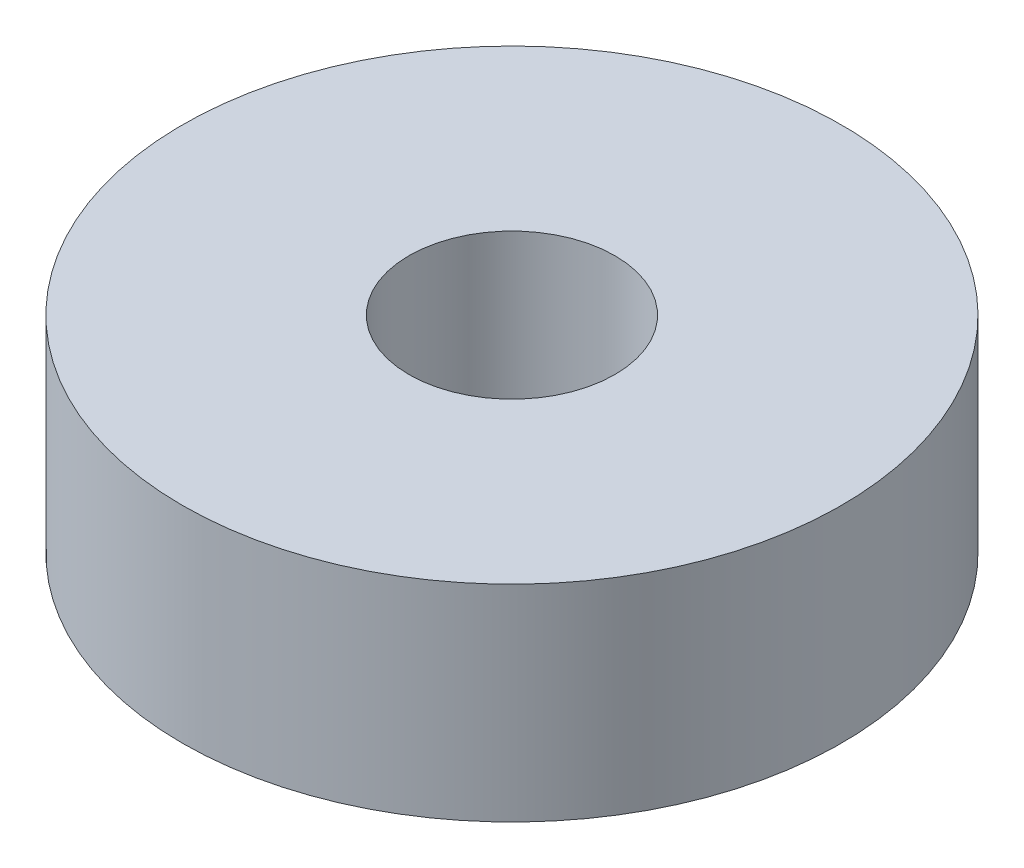
from build123d import *

# Parameters (mm, degrees)
SKETCH1_R           = 8
SKETCH1_R_2         = 2.5
BOSS_EXTRUDE1_DEPTH = 5


with BuildPart() as part:
    # Sketch1 → Boss-Extrude1 (new body)
    with BuildSketch(Plane(origin=(0, 0, 0), x_dir=(1, 0, 0), z_dir=(0, 1, 0))):
        Circle(SKETCH1_R)
        Circle(SKETCH1_R_2, mode=Mode.SUBTRACT)
    extrude(amount=BOSS_EXTRUDE1_DEPTH)


solid = part.part
